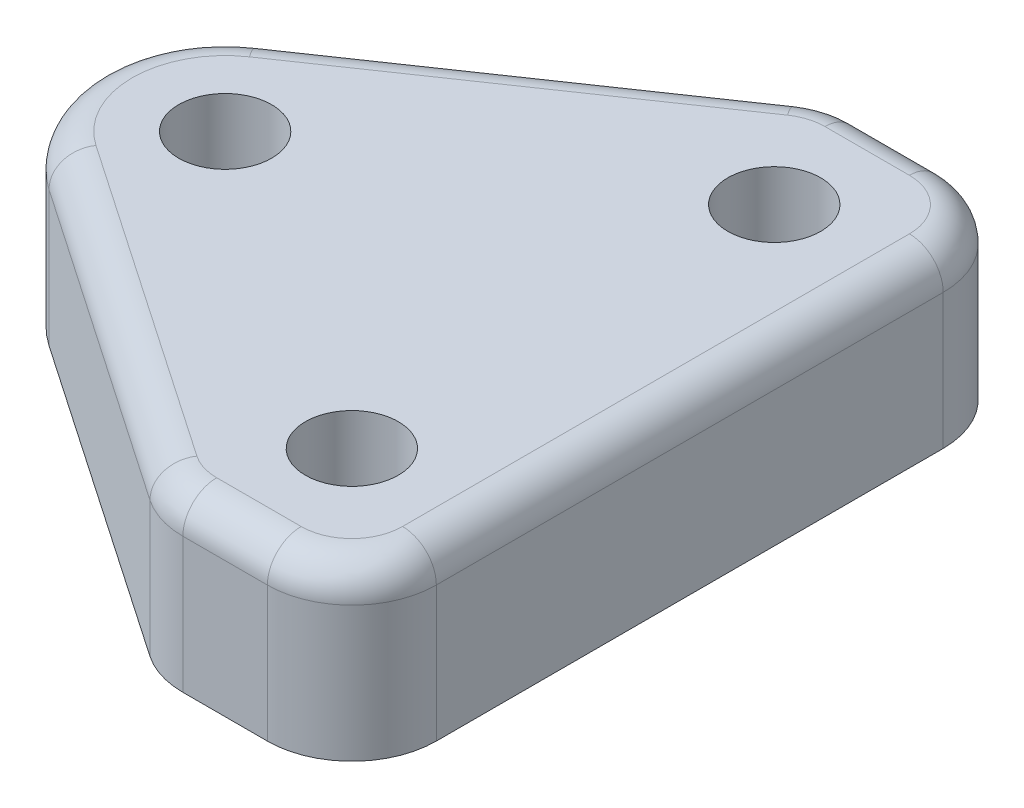
from build123d import *

# Parameters (mm, degrees)
BOSS_EXTRUDE1_DEPTH  = 10
M5_CLEARANCE_HOLE1_D = 5.5
FILLET1_R            = 2


with BuildPart() as part:
    # Sketch1 → Boss-Extrude1 (new body)
    with BuildSketch(Plane(origin=(0, 0, 0), x_dir=(1, 0, 0), z_dir=(0, 1, 0))):
        with BuildLine():
            Line((-4.234491912, -6.190240564), (14.677005392, -19.126827043))
            ThreePointArc((14.677005392, -19.126827043), (16.022524994, -19.776721429), (17.5, -20))
            Line((17.5, -20), (22.5, -20))
            ThreePointArc((22.5, -20), (26.035533906, -18.535533906), (27.5, -15))
            Line((27.5, -15), (27.5, 15))
            ThreePointArc((27.5, 15), (26.035533906, 18.535533906), (22.5, 20))
            Line((22.5, 20), (17.5, 20))
            ThreePointArc((17.5, 20), (16.022524994, 19.776721429), (14.677005392, 19.126827043))
            Line((14.677005392, 19.126827043), (-4.234491912, 6.190240564))
            ThreePointArc((-4.234491912, 6.190240564), (-7.5, 0), (-4.234491912, -6.190240564))
        make_face()
    extrude(amount=BOSS_EXTRUDE1_DEPTH)

    # M5 Clearance Hole1 (through all)
    with Locations(Plane(origin=(0, 10, 0), x_dir=(1, 0, 0), z_dir=(0, 1, 0))):
        with Locations((0, 0), (20, 12.5), (20, -12.5)):
            Hole(M5_CLEARANCE_HOLE1_D / 2)

    # Fillet1
    fillet1_edges = [part.edges().sort_by_distance(p)[0] for p in [
        (5.22125674, 10, -12.658533804),
        (16.022524994, 10, -19.776721429),
        (20, 10, -20),
        (26.035533906, 10, -18.535533906),
        (27.5, 10, 0),
        (26.035533906, 10, 18.535533906),
        (20, 10, 20),
        (16.022524994, 10, 19.776721429),
        (5.22125674, 10, 12.658533804),
        (-7.5, 10, 0),
    ]]
    fillet(fillet1_edges, radius=FILLET1_R)


solid = part.part
